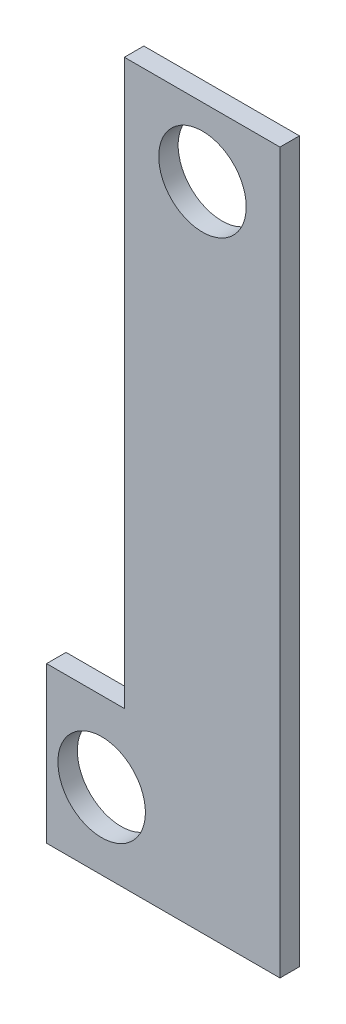
from build123d import *

# Parameters (mm, degrees)
BOSS_EXTRUDE1_DEPTH = 6.35
SKETCH2_R           = 14.2875
CUT_EXTRUDE1_DEPTH  = 6.35


with BuildPart() as part:
    # Sketch1 → Boss-Extrude1 (new body)
    with BuildSketch(Plane.XY):
        Polygon((0, 0), (76.2, 0), (76.2, 234.95), (25.4, 234.95), (25.4, 50.8), (0, 50.8), align=None)
    extrude(amount=BOSS_EXTRUDE1_DEPTH)

    # Sketch2 → Cut-Extrude1 (cut)
    with BuildSketch(Plane.XY.offset(6.35)):
        with Locations((17.982492959, 24.849632573)):
            Circle(SKETCH2_R)
        with Locations((50.8967853, 212.524849319)):
            Circle(SKETCH2_R)
    extrude(amount=-CUT_EXTRUDE1_DEPTH, mode=Mode.SUBTRACT)


solid = part.part
